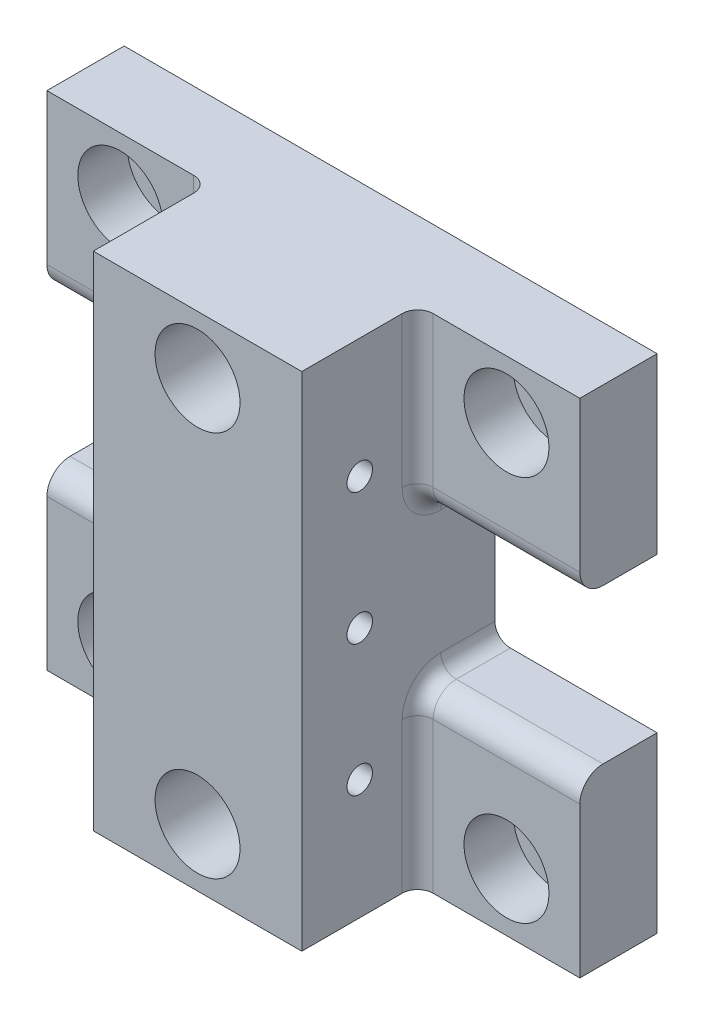
from build123d import *

# Parameters (mm, degrees)
SKETCH_1_W                  = 69
SKETCH_1_H                  = 65
EXTRUDE_1_DEPTH             = 10
SKETCH_2_W                  = 27
SKETCH_2_H                  = 65
EXTRUDE_2_DEPTH             = 15
SKETCH_3_W                  = 10
SKETCH_3_H                  = 20
CUT_EXTRUDE_1_DEPTH         = 22
FILLET_1_R                  = 3
FILLET_2_R                  = 2
PATTERN_LINEAR_2_COUNT      = 2
PATTERN_LINEAR_2_PITCH      = 17
PATTERN_LINEAR_2_COL_COUNT  = 2
PATTERN_LINEAR_2_COL_PITCH  = 17
HOLE_WIZARD_M6_1_AT_2_COUNT = 2
HOLE_WIZARD_M6_1_AT_2_PITCH = 50
HOLE_WIZARD_M6_1_AT_3_COUNT = 2
HOLE_WIZARD_M6_1_AT_3_PITCH = 70.710678119
HOLE_WIZARD_M6_1_AT_4_COUNT = 2
HOLE_WIZARD_M6_1_AT_4_PITCH = 50
HOLE_WIZARD_M6_1_AT_5_COUNT = 2
HOLE_WIZARD_M6_1_AT_5_PITCH = 25
HOLE_WIZARD_M6_1_AT_6_COUNT = 2
HOLE_WIZARD_M6_1_AT_6_PITCH = 55.901699437
SKETCH_15_R                 = 5.5
CUT_EXTRUDE_3_DEPTH         = 16


with BuildPart() as part:
    # 스케치1 → 보스-돌출1 (new body)
    with BuildSketch(Plane.XY):
        Rectangle(SKETCH_1_W, SKETCH_1_H)
    extrude(amount=EXTRUDE_1_DEPTH)

    # 스케치2 → 보스-돌출2 (add)
    with BuildSketch(Plane.XY.offset(10)):
        Rectangle(SKETCH_2_W, SKETCH_2_H)
    extrude(amount=EXTRUDE_2_DEPTH)

    # 스케치3 → 컷-돌출1 (cut, through all)
    with BuildSketch(Plane(origin=(13.5, 0, 0), x_dir=(0, 0, -1), z_dir=(1, 0, 0))):
        with Locations((-5, 0)):
            Rectangle(SKETCH_3_W, SKETCH_3_H)
    cut_extrude_1 = extrude(amount=CUT_EXTRUDE_1_DEPTH, mode=Mode.SUBTRACT)

    # 대칭 복사1: 컷-돌출1 across plane
    add(cut_extrude_1.mirror(Plane(origin=(0, 0, 0), x_dir=(0, 0, 1), z_dir=(1, 0, 0))), mode=Mode.SUBTRACT)

    # 필렛1
    fillet_1_edges = [part.edges().sort_by_distance(p)[0] for p in [
        (24, 10, 10),
        (24, -10, 10),
        (-24, -10, 10),
        (-24, 10, 10),
    ]]
    fillet(fillet_1_edges, radius=FILLET_1_R)

    # 필렛2
    fillet_2_edges = [part.edges().sort_by_distance(p)[0] for p in [
        (13.5, -22.75, 10),
        (-13.5, 22.75, 10),
        (13.5, 10, 3.5),
        (-13.5, 10, 3.5),
        (-13.5, -10, 3.5),
        (-13.5, -22.75, 10),
        (13.5, -10, 3.5),
        (13.5, 22.75, 10),
        (-13.5, -10.878679656, 9.121320344),
        (-13.5, 10.878679656, 9.121320344),
        (13.5, -10.878679656, 9.121320344),
        (13.5, 10.878679656, 9.121320344),
    ]]
    fillet(fillet_2_edges, radius=FILLET_2_R)

    # 스케치8 → M4 탭을 위한 탭 드릴1 (revolve, cut)
    with BuildSketch(Plane(origin=(13.5, 0, 17.5), x_dir=(0, 0, -1), z_dir=(0, 1, 0))):
        Polygon((0, 0), (0, 7.991420021), (1.65, 7), (1.65, 0), align=None)
    hole_wizard_m4_1 = revolve(axis=Axis((19.85, 0, 17.5), (-1, 0, 0)), mode=Mode.SUBTRACT)

    # 선형 패턴2: M4 탭을 위한 탭 드릴1 ×2
    with Locations(*[(0, -i * PATTERN_LINEAR_2_PITCH, 0) for i in range(1, PATTERN_LINEAR_2_COUNT)]):
        add(hole_wizard_m4_1, mode=Mode.SUBTRACT)

    # 선형 패턴2 col: M4 탭을 위한 탭 드릴1 ×2
    with Locations(*[(0, i * PATTERN_LINEAR_2_COL_PITCH, 0) for i in range(1, PATTERN_LINEAR_2_COL_COUNT)]):
        add(hole_wizard_m4_1, mode=Mode.SUBTRACT)

    # 대칭 복사3: M4 탭을 위한 탭 드릴1 across plane
    add(hole_wizard_m4_1.mirror(Plane(origin=(0, 0, 0), x_dir=(0, 0, 1), z_dir=(1, 0, 0))), mode=Mode.SUBTRACT)

    # 대칭 복사3 copy 1 sketch → 대칭 복사3 copy 1 (revolve, cut)
    with BuildSketch(Plane(origin=(-13.5, -17, 17.5), x_dir=(0, 0, -1), z_dir=(0, 1, 0))):
        Polygon((0, 0), (0, -7.991420021), (1.65, -7), (1.65, 0), align=None)
    revolve(axis=Axis((-19.85, -17, 17.5), (-1, 0, 0)), mode=Mode.SUBTRACT)

    # 대칭 복사3 copy 2 sketch → 대칭 복사3 copy 2 (revolve, cut)
    with BuildSketch(Plane(origin=(-13.5, 17, 17.5), x_dir=(0, 0, -1), z_dir=(0, 1, 0))):
        Polygon((0, 0), (0, -7.991420021), (1.65, -7), (1.65, 0), align=None)
    revolve(axis=Axis((-19.85, 17, 17.5), (-1, 0, 0)), mode=Mode.SUBTRACT)

    # 스케치14 → M6 육각 소켓 머리 캡 나사용 카운터보어1 (revolve, cut)
    with BuildSketch(Plane(origin=(-25, 25, 10), x_dir=(0, -1, 0), z_dir=(1, 0, 0))):
        Polygon((0, 0), (0, 10), (3.2, 10), (3.2, 6.4), (5.5, 6.4), (5.5, 0), align=None)
    hole_wizard_m6_1 = revolve(axis=Axis((-25, 25, 16.35), (0, 0, -1)), mode=Mode.SUBTRACT)

    # M6 육각 소켓 머리 캡 나사용 카운터보어1 at 2: M6 육각 소켓 머리 캡 나사용 카운터보어1 ×2
    with Locations(*[(0, -i * HOLE_WIZARD_M6_1_AT_2_PITCH, 0) for i in range(1, HOLE_WIZARD_M6_1_AT_2_COUNT)]):
        add(hole_wizard_m6_1, mode=Mode.SUBTRACT)

    # M6 육각 소켓 머리 캡 나사용 카운터보어1 at 3: M6 육각 소켓 머리 캡 나사용 카운터보어1 ×2
    with Locations(*[Vector(0.707106781, -0.707106781, 0) * (i * HOLE_WIZARD_M6_1_AT_3_PITCH) for i in range(1, HOLE_WIZARD_M6_1_AT_3_COUNT)]):
        add(hole_wizard_m6_1, mode=Mode.SUBTRACT)

    # M6 육각 소켓 머리 캡 나사용 카운터보어1 at 4: M6 육각 소켓 머리 캡 나사용 카운터보어1 ×2
    with Locations(*[(i * HOLE_WIZARD_M6_1_AT_4_PITCH, 0, 0) for i in range(1, HOLE_WIZARD_M6_1_AT_4_COUNT)]):
        add(hole_wizard_m6_1, mode=Mode.SUBTRACT)

    # M6 육각 소켓 머리 캡 나사용 카운터보어1 at 5: M6 육각 소켓 머리 캡 나사용 카운터보어1 ×2
    with Locations(*[(i * HOLE_WIZARD_M6_1_AT_5_PITCH, 0, 0) for i in range(1, HOLE_WIZARD_M6_1_AT_5_COUNT)]):
        add(hole_wizard_m6_1, mode=Mode.SUBTRACT)

    # M6 육각 소켓 머리 캡 나사용 카운터보어1 at 6: M6 육각 소켓 머리 캡 나사용 카운터보어1 ×2
    with Locations(*[Vector(0.447213595, -0.894427191, 0) * (i * HOLE_WIZARD_M6_1_AT_6_PITCH) for i in range(1, HOLE_WIZARD_M6_1_AT_6_COUNT)]):
        add(hole_wizard_m6_1, mode=Mode.SUBTRACT)

    # 스케치15 → 컷-돌출3 (cut, through all)
    with BuildSketch(Plane(origin=(0, 0, 10), x_dir=(-1, 0, 0), z_dir=(0, 0, -1))):
        with Locations((0, -25)):
            Circle(SKETCH_15_R)
        with Locations((0, 25)):
            Circle(SKETCH_15_R)
    extrude(amount=-CUT_EXTRUDE_3_DEPTH, mode=Mode.SUBTRACT)


solid = part.part
